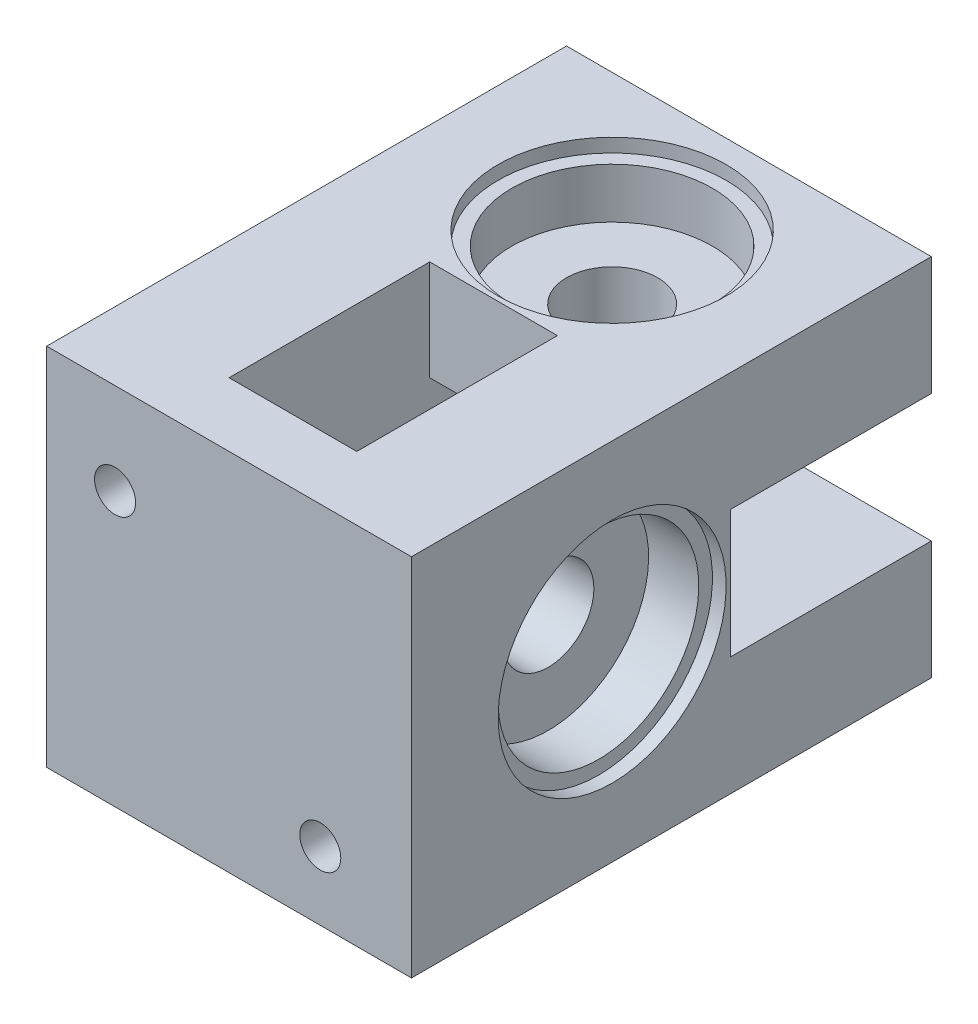
from build123d import *

# Parameters (mm, degrees)
ESQUISSE1_W              = 40
ESQUISSE1_H              = 40
BOSS_EXTRU_1_DEPTH       = 50
ESQUISSE2_R              = 5
ENL_V_MAT_EXTRU_1_DEPTH  = 41
ESQUISSE3_R              = 5
ENL_V_MAT_EXTRU_2_DEPTH  = 41
ESQUISSE4_W              = 20
ESQUISSE4_H              = 14
ENL_V_MAT_EXTRU_3_DEPTH  = 29
ESQUISSE5_W              = 14
ESQUISSE5_H              = 20
ENL_V_MAT_EXTRU_4_DEPTH  = 29
ESQUISSE6_W              = 22
ESQUISSE6_H              = 14
ENL_V_MAT_EXTRU_5_DEPTH  = 24
ESQUISSE7_W              = 14
ESQUISSE7_H              = 22
ENL_V_MAT_EXTRU_6_DEPTH  = 24
ESQUISSE8_R              = 11
ENL_V_MAT_EXTRU_7_DEPTH  = 7
ESQUISSE9_R              = 12.5
ENL_V_MAT_EXTRU_8_DEPTH  = 1.5
ESQUISSE10_R             = 11
ENL_V_MAT_EXTRU_9_DEPTH  = 7
ESQUISSE11_R             = 12.5
ENL_V_MAT_EXTRU_10_DEPTH = 1.5
ESQUISSE12_W             = 40
ESQUISSE12_H             = 40
BOSS_EXTRU_2_DEPTH       = 7
ESQUISSE13_R             = 2.25
ENL_V_MAT_EXTRU_11_DEPTH = 15
ESQUISSE14_W             = 7.5
ESQUISSE14_H             = 3.5
ENL_V_MAT_EXTRU_12_DEPTH = 12
ESQUISSE15_W             = 3.5
ESQUISSE15_H             = 7.5
ENL_V_MAT_EXTRU_13_DEPTH = 12


with BuildPart() as part:
    # Esquisse1 → Boss.-Extru.1 (new body)
    with BuildSketch(Plane.XY):
        with Locations((-20, 20)):
            Rectangle(ESQUISSE1_W, ESQUISSE1_H)
    extrude(amount=BOSS_EXTRU_1_DEPTH)

    # Esquisse2 → Enlèv. mat.-Extru.1 (cut, through all)
    with BuildSketch(Plane(origin=(0, 40, 0), x_dir=(1, 0, 0), z_dir=(0, 1, 0))):
        with Locations(Location((-20, -15, 0), (0, 0, 270))):  # turned: the seam where the file's is
            Circle(ESQUISSE2_R)
    extrude(amount=-ENL_V_MAT_EXTRU_1_DEPTH, mode=Mode.SUBTRACT)

    # Esquisse3 → Enlèv. mat.-Extru.2 (cut, through all)
    with BuildSketch(Plane.ZY.offset(40)):
        with Locations((35, 20)):
            Circle(ESQUISSE3_R)
    extrude(amount=-ENL_V_MAT_EXTRU_2_DEPTH, mode=Mode.SUBTRACT)

    # Esquisse4 → Enlèv. mat.-Extru.3 (cut)
    with BuildSketch(Plane.ZY.offset(40)):
        with Locations((15, 20)):
            Rectangle(ESQUISSE4_W, ESQUISSE4_H)
    extrude(amount=-ENL_V_MAT_EXTRU_3_DEPTH, mode=Mode.SUBTRACT)

    # Esquisse5 → Enlèv. mat.-Extru.4 (cut)
    with BuildSketch(Plane.XZ):
        with Locations((-20, 35)):
            Rectangle(ESQUISSE5_W, ESQUISSE5_H)
    extrude(amount=-ENL_V_MAT_EXTRU_4_DEPTH, mode=Mode.SUBTRACT)

    # Esquisse6 → Enlèv. mat.-Extru.5 (cut)
    with BuildSketch(Plane(origin=(0, 0, 0), x_dir=(0, 0, -1), z_dir=(1, 0, 0))):
        with Locations((-11, 20)):
            Rectangle(ESQUISSE6_W, ESQUISSE6_H)
    extrude(amount=-ENL_V_MAT_EXTRU_5_DEPTH, mode=Mode.SUBTRACT)

    # Esquisse7 → Enlèv. mat.-Extru.6 (cut)
    with BuildSketch(Plane(origin=(0, 40, 0), x_dir=(1, 0, 0), z_dir=(0, 1, 0))):
        with Locations((-20, -39)):
            Rectangle(ESQUISSE7_W, ESQUISSE7_H)
    extrude(amount=-ENL_V_MAT_EXTRU_6_DEPTH, mode=Mode.SUBTRACT)

    # Esquisse8 → Enlèv. mat.-Extru.7 (cut)
    with BuildSketch(Plane(origin=(0, 0, 0), x_dir=(0, 0, -1), z_dir=(1, 0, 0))):
        with Locations(Location((-35, 20, 0), (0, 0, 90))):  # turned: the seam where the file's is
            Circle(ESQUISSE8_R)
    extrude(amount=-ENL_V_MAT_EXTRU_7_DEPTH, mode=Mode.SUBTRACT)

    # Esquisse9 → Enlèv. mat.-Extru.8 (cut)
    with BuildSketch(Plane(origin=(0, 0, 0), x_dir=(0, 0, -1), z_dir=(1, 0, 0))):
        with Locations(Location((-35, 20, 0), (0, 0, 90))):  # turned: the seam where the file's is
            Circle(ESQUISSE9_R)
    extrude(amount=-ENL_V_MAT_EXTRU_8_DEPTH, mode=Mode.SUBTRACT)

    # Esquisse10 → Enlèv. mat.-Extru.9 (cut)
    with BuildSketch(Plane(origin=(0, 40, 0), x_dir=(1, 0, 0), z_dir=(0, 1, 0))):
        with Locations(Location((-20, -15, 0), (0, 0, 270))):  # turned: the seam where the file's is
            Circle(ESQUISSE10_R)
    extrude(amount=-ENL_V_MAT_EXTRU_9_DEPTH, mode=Mode.SUBTRACT)

    # Esquisse11 → Enlèv. mat.-Extru.10 (cut)
    with BuildSketch(Plane(origin=(0, 40, 0), x_dir=(1, 0, 0), z_dir=(0, 1, 0))):
        with Locations(Location((-20, -15, 0), (0, 0, 270))):  # turned: the seam where the file's is
            Circle(ESQUISSE11_R)
    extrude(amount=-ENL_V_MAT_EXTRU_10_DEPTH, mode=Mode.SUBTRACT)

    # Esquisse12 → Boss.-Extru.2 (add)
    with BuildSketch(Plane.XY.offset(50)):
        with Locations((-20, 20)):
            Rectangle(ESQUISSE12_W, ESQUISSE12_H)
    extrude(amount=BOSS_EXTRU_2_DEPTH)

    # Esquisse13 → Enlèv. mat.-Extru.11 (cut)
    with BuildSketch(Plane.XY.offset(57)):
        with Locations((-32.5, 30)):
            Circle(ESQUISSE13_R)
        with Locations((-10, 7.5)):
            Circle(ESQUISSE13_R)
    extrude(amount=-ENL_V_MAT_EXTRU_11_DEPTH, mode=Mode.SUBTRACT)

    # Esquisse14 → Enlèv. mat.-Extru.12 (cut)
    with BuildSketch(Plane.XZ):
        with Locations((-10, 51.25)):
            Rectangle(ESQUISSE14_W, ESQUISSE14_H)
    extrude(amount=-ENL_V_MAT_EXTRU_12_DEPTH, mode=Mode.SUBTRACT)

    # Esquisse15 → Enlèv. mat.-Extru.13 (cut)
    with BuildSketch(Plane.ZY.offset(40)):
        with Locations((51.25, 30)):
            Rectangle(ESQUISSE15_W, ESQUISSE15_H)
    extrude(amount=-ENL_V_MAT_EXTRU_13_DEPTH, mode=Mode.SUBTRACT)


solid = part.part
